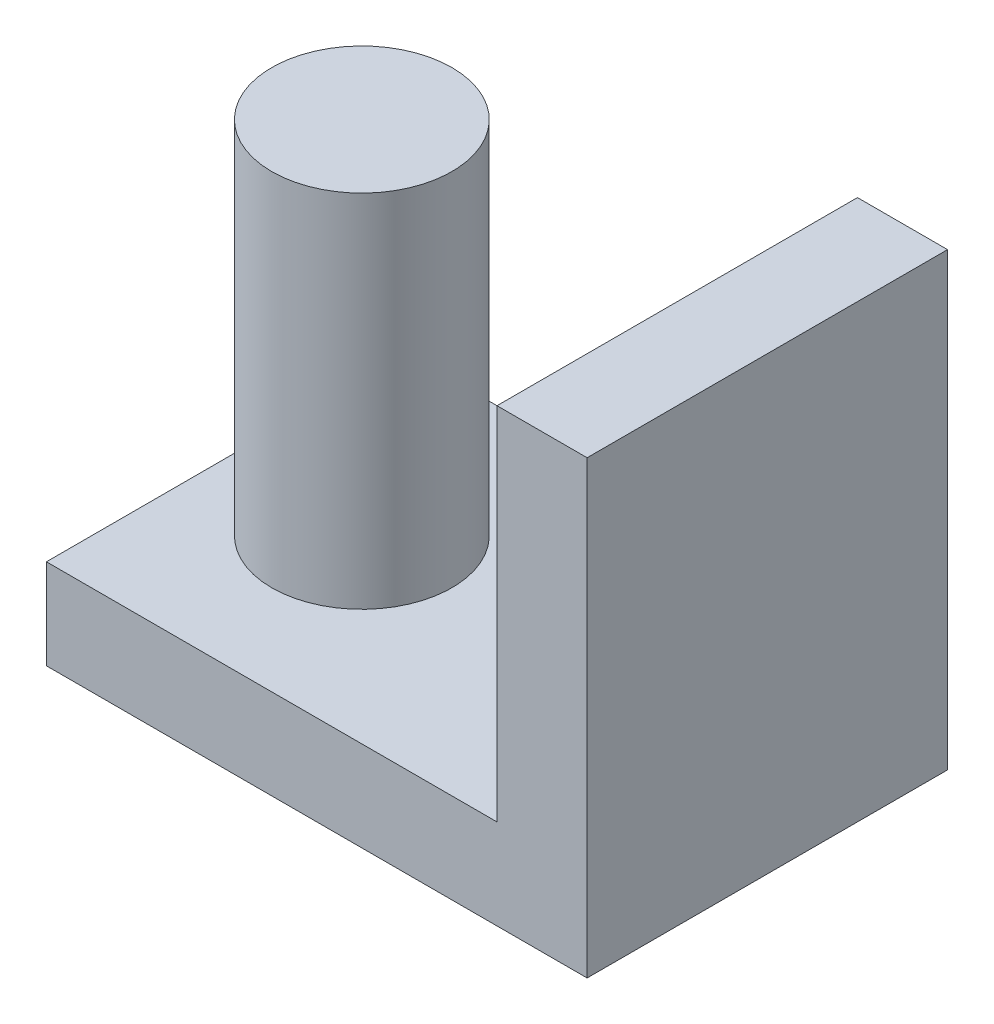
from build123d import *

# Parameters (mm, degrees)
SKETCH1_W           = 9.525
SKETCH1_H           = 6.35
BOSS_EXTRUDE1_DEPTH = 1.5875
SKETCH2_R           = 1.5875
SKETCH2_W           = 1.5875
SKETCH2_H           = 6.35
BOSS_EXTRUDE2_DEPTH = 6.35


with BuildPart() as part:
    # Sketch1 → Boss-Extrude1 (new body)
    with BuildSketch(Plane(origin=(0, 0, 0), x_dir=(1, 0, 0), z_dir=(0, 1, 0))):
        Rectangle(SKETCH1_W, SKETCH1_H)
    extrude(amount=BOSS_EXTRUDE1_DEPTH)

    # Sketch2 → Boss-Extrude2 (add)
    with BuildSketch(Plane(origin=(0, 1.5875, 0), x_dir=(1, 0, 0), z_dir=(0, 1, 0))):
        with Locations((-2.38125, 0)):
            Circle(SKETCH2_R)
        with Locations((3.96875, 0)):
            Rectangle(SKETCH2_W, SKETCH2_H)
    extrude(amount=BOSS_EXTRUDE2_DEPTH)


solid = part.part
